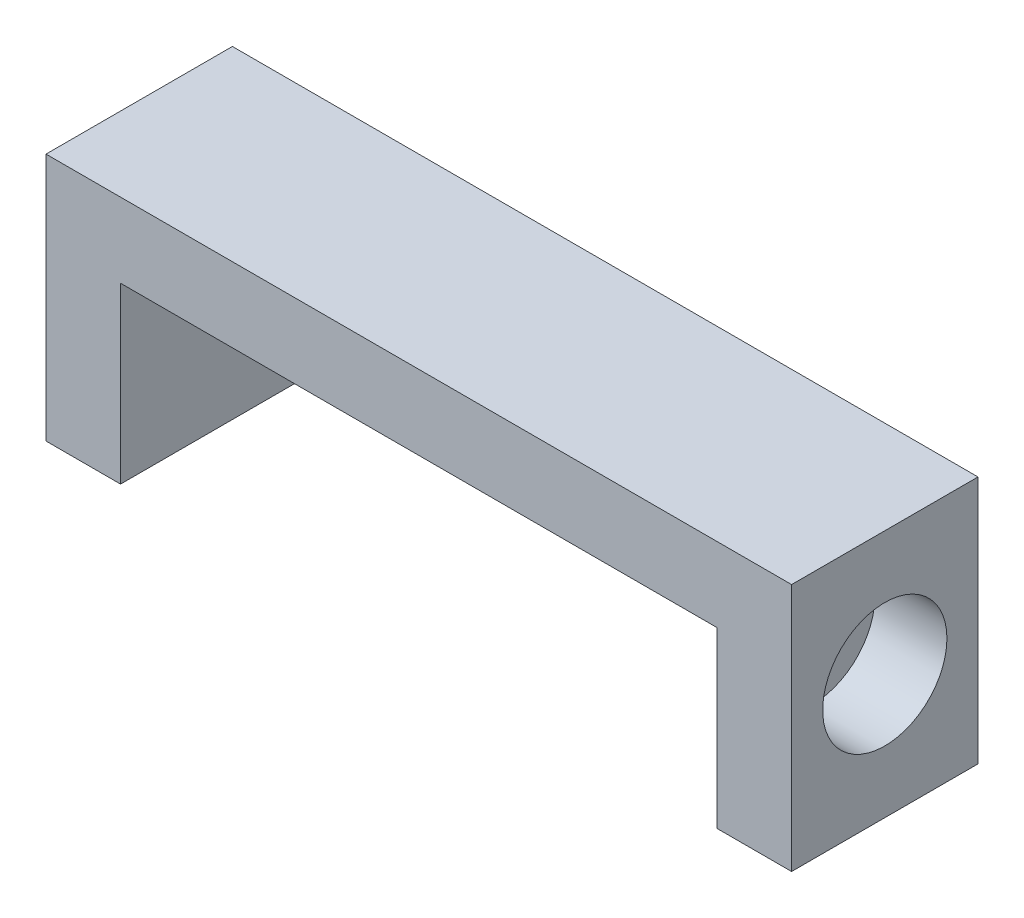
from build123d import *

# Parameters (mm, degrees)
SKETCH1_W               = 30
SKETCH1_H               = 10
BOSS_EXTRUDE1_DEPTH     = 3.75
CUT_EXTRUDE1_REACH      = 9.5
SKETCH2_W               = 24
SKETCH2_H               = 7
SKETCH4_R               = 2.5
CUT_EXTRUDE2_DEPTH      = 16
CUT_EXTRUDE2_DEPTH_BACK = 16
BOSS_EXTRUDE2_START     = -3
SKETCH5_R               = 2.5
BOSS_EXTRUDE2_DEPTH     = 0.1
BOSS_EXTRUDE3_START     = -3
SKETCH6_R               = 2.5
BOSS_EXTRUDE3_DEPTH     = 0.1
SKETCH7_W               = 24
SKETCH7_H               = 3
BOSS_EXTRUDE4_DEPTH     = 7.5


with BuildPart() as part:
    # Sketch1 → Boss-Extrude1 (new body, symmetric)
    with BuildSketch(Plane.XY):
        Rectangle(SKETCH1_W, SKETCH1_H)
    extrude(amount=BOSS_EXTRUDE1_DEPTH, both=True)

    # Sketch2 → Cut-Extrude1 (cut, up to next)
    with BuildSketch(Plane.XY.offset(3.75), mode=Mode.PRIVATE) as cut_extrude1_sk1:
        with Locations((0, -1.5)):
            Rectangle(SKETCH2_W, SKETCH2_H)
    cut_extrude1_tool1 = extrude(cut_extrude1_sk1.sketch, amount=-CUT_EXTRUDE1_REACH, mode=Mode.PRIVATE) & part.part
    add(cut_extrude1_tool1.solids().sort_by_distance((0, -1.5, 3.75))[0], mode=Mode.SUBTRACT)

    # Sketch4 → Cut-Extrude2 (cut, two sides)
    with BuildSketch(Plane(origin=(0, 0, 0), x_dir=(0, 0, -1), z_dir=(1, 0, 0))) as cut_extrude2_sk:
        Circle(SKETCH4_R)
    extrude(amount=CUT_EXTRUDE2_DEPTH, mode=Mode.SUBTRACT)
    extrude(cut_extrude2_sk.sketch, amount=-CUT_EXTRUDE2_DEPTH_BACK, mode=Mode.SUBTRACT)

    # Sketch5 → Boss-Extrude2 (add)
    with BuildSketch(Plane(origin=(15, 0, 0), x_dir=(0, 0, -1), z_dir=(1, 0, 0)).offset(BOSS_EXTRUDE2_START)):
        Circle(SKETCH5_R)
    extrude(amount=BOSS_EXTRUDE2_DEPTH)

    # Sketch6 → Boss-Extrude3 (add)
    with BuildSketch(Plane.ZY.offset(15).offset(BOSS_EXTRUDE3_START)):
        Circle(SKETCH6_R)
    extrude(amount=BOSS_EXTRUDE3_DEPTH)

    # Sketch7 → Boss-Extrude4 (add)
    with BuildSketch(Plane(origin=(0, 0, -3.75), x_dir=(-1, 0, 0), z_dir=(0, 0, -1))):
        with Locations((0, 3.5)):
            Rectangle(SKETCH7_W, SKETCH7_H)
    extrude(amount=-BOSS_EXTRUDE4_DEPTH)


solid = part.part
